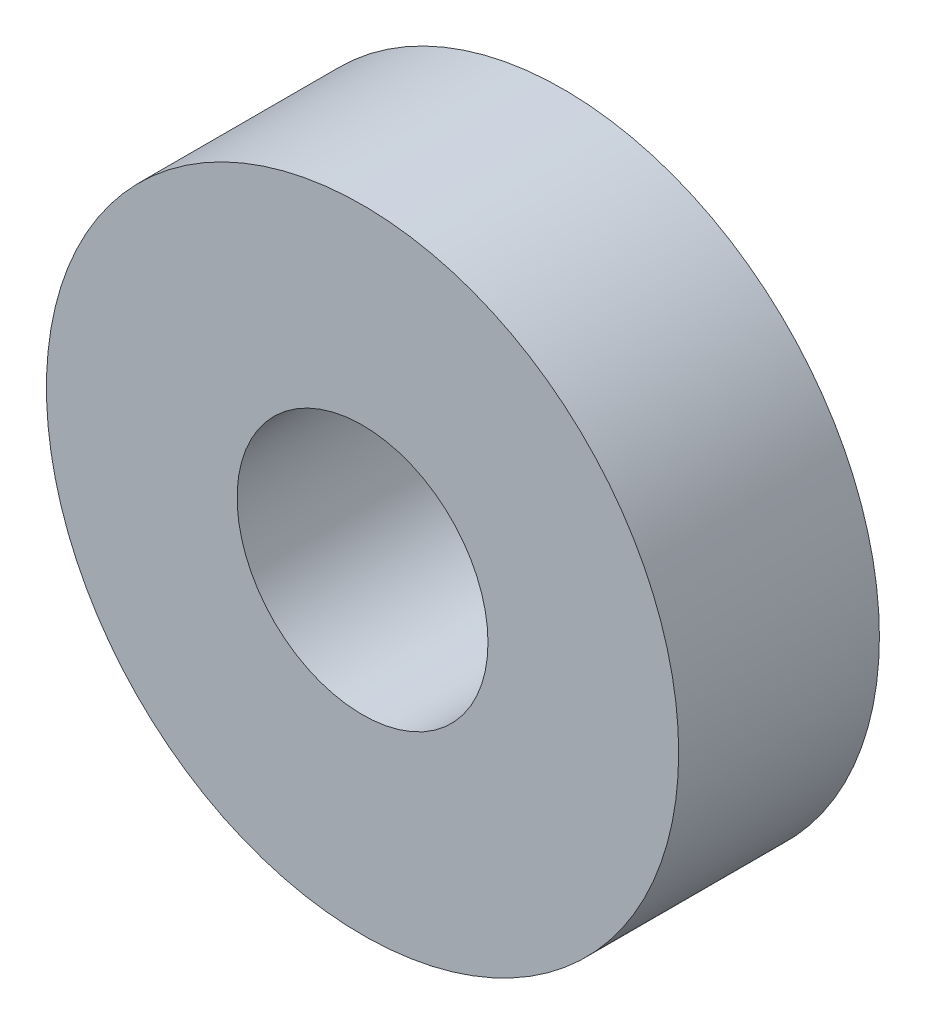
from build123d import *

# Parameters (mm, degrees)
ESQUISSE1_R        = 15.75
ESQUISSE1_R_2      = 6.25
BOSS_EXTRU_1_DEPTH = 10


with BuildPart() as part:
    # Esquisse1 → Boss.-Extru.1 (new body)
    with BuildSketch(Plane.XY):
        Circle(ESQUISSE1_R)
        Circle(ESQUISSE1_R_2, mode=Mode.SUBTRACT)
    extrude(amount=BOSS_EXTRU_1_DEPTH)


solid = part.part
